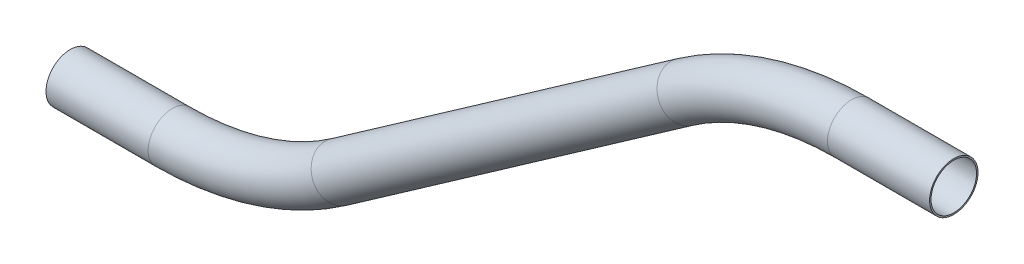
from build123d import *

# Parameters (mm, degrees)
SKETCH5_R   = 6.35
SKETCH5_R_2 = 5.969


with BuildPart() as part:
    # Sweep1: sweep along a path in Sketch4
    with BuildLine(Plane.XY) as sweep1_path:
        Line((127.067542117, 51.074736957), (100.29330983, 51.074736957))
        ThreePointArc((100.29330983, 51.074736957), (77.379527908, 47.547968604), (56.58678538, 37.294122732))
        Line((56.58678538, 37.294122732), (-34.092088176, -26.199908089))
        ThreePointArc((-34.092088176, -26.199908089), (-54.884830704, -36.453753961), (-77.798612626, -39.980522314))
        Line((-77.798612626, -39.980522314), (-104.572844914, -39.980522314))
    # Sketch5 → Sweep1 (sweep)
    with BuildSketch(Plane(origin=(127.067542117, 51.074736957, 0), x_dir=(0, 0, 1), z_dir=(-1, 0, 0))):
        Circle(SKETCH5_R)
        Circle(SKETCH5_R_2, mode=Mode.SUBTRACT)
    sweep(path=sweep1_path.line)


solid = part.part
